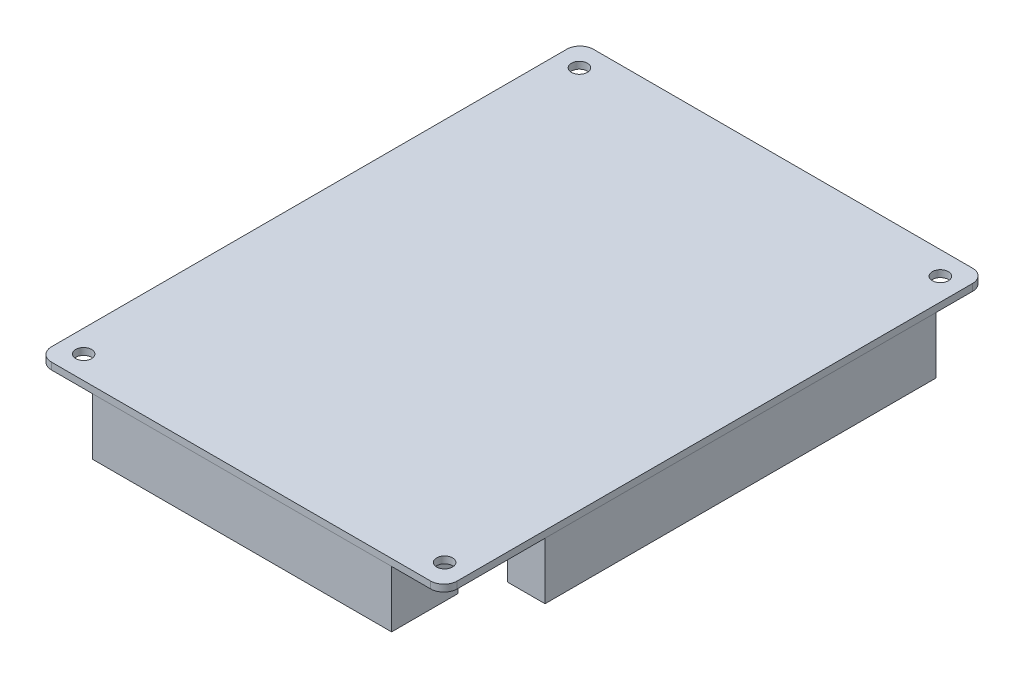
from build123d import *

# Parameters (mm, degrees)
SKETCH1_W                = 91.5
SKETCH1_H                = 122.2
BOSS_EXTRUDE1_DEPTH      = 1.5494
M3_CLEARANCE_HOLE1_D     = 3.6
M3_CLEARANCE_HOLE1_DEPTH = 12
FILLET1_R                = 3
SKETCH4_W                = 8.5
SKETCH4_H                = 88.2
SKETCH4_W_2              = 49.5
SKETCH4_H_2              = 7.5
SKETCH4_H_3              = 90.2
SKETCH4_W_3              = 67.5
SKETCH4_H_4              = 15
BOSS_EXTRUDE2_DEPTH      = 13


with BuildPart() as part:
    # Sketch1 → Boss-Extrude1 (new body)
    with BuildSketch(Plane(origin=(0, 0, 0), x_dir=(1, 0, 0), z_dir=(0, 1, 0))):
        Rectangle(SKETCH1_W, SKETCH1_H)
    extrude(amount=BOSS_EXTRUDE1_DEPTH)

    # M3 Clearance Hole1
    with Locations(Plane(origin=(0, 1.5494, 0), x_dir=(1, 0, 0), z_dir=(0, 1, 0))):
        with Locations((-40.7, 55.9), (40.7, -55.9), (40.7, 55.9), (-40.7, -55.9)):
            Hole(M3_CLEARANCE_HOLE1_D / 2, depth=M3_CLEARANCE_HOLE1_DEPTH)

    # Fillet1
    fillet1_edges = [part.edges().sort_by_distance(p)[0] for p in [
        (-45.75, 0.7747, -61.1),
        (45.75, 0.7747, -61.1),
        (45.75, 0.7747, 61.1),
        (-45.75, 0.7747, 61.1),
    ]]
    fillet(fillet1_edges, radius=FILLET1_R)

    # Sketch4 → Boss-Extrude2 (add)
    with BuildSketch(Plane.XZ):
        with Locations((41.3, -6)):
            Rectangle(SKETCH4_W, SKETCH4_H)
        with Locations((-6, -57.15)):
            Rectangle(SKETCH4_W_2, SKETCH4_H_2)
        with Locations((-41.3, -5)):
            Rectangle(SKETCH4_W, SKETCH4_H_3)
        with Locations((0, 53.4)):
            Rectangle(SKETCH4_W_3, SKETCH4_H_4)
    extrude(amount=BOSS_EXTRUDE2_DEPTH)


solid = part.part
